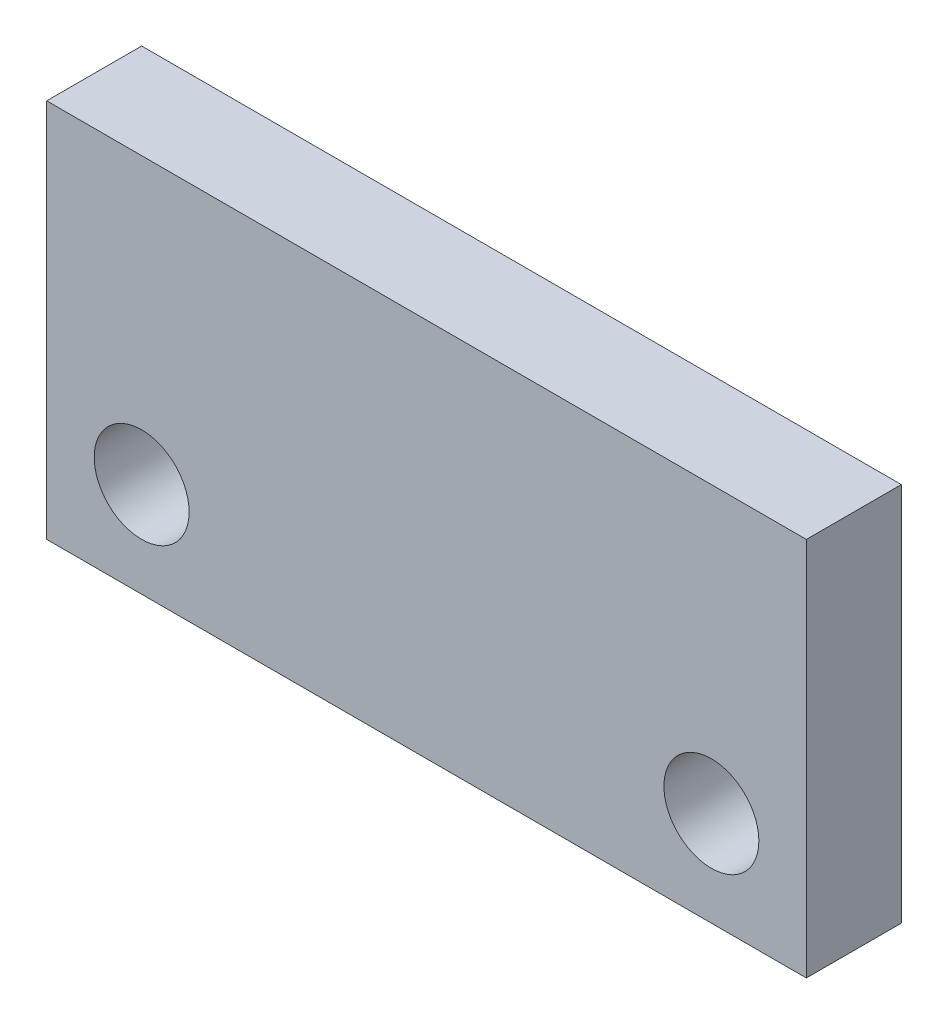
from build123d import *

# Parameters (mm, degrees)
SKETCH1_W           = 50.8
SKETCH1_H           = 25.4
SKETCH1_R           = 3.175
BOSS_EXTRUDE1_DEPTH = 6.35


with BuildPart() as part:
    # Sketch1 → Boss-Extrude1 (new body)
    with BuildSketch(Plane.XY):
        with Locations((25.4, 12.7)):
            Rectangle(SKETCH1_W, SKETCH1_H)
        with Locations((6.35, 6.35)):
            Circle(SKETCH1_R, mode=Mode.SUBTRACT)
        with Locations((44.45, 6.35)):
            Circle(SKETCH1_R, mode=Mode.SUBTRACT)
    extrude(amount=BOSS_EXTRUDE1_DEPTH)


solid = part.part
